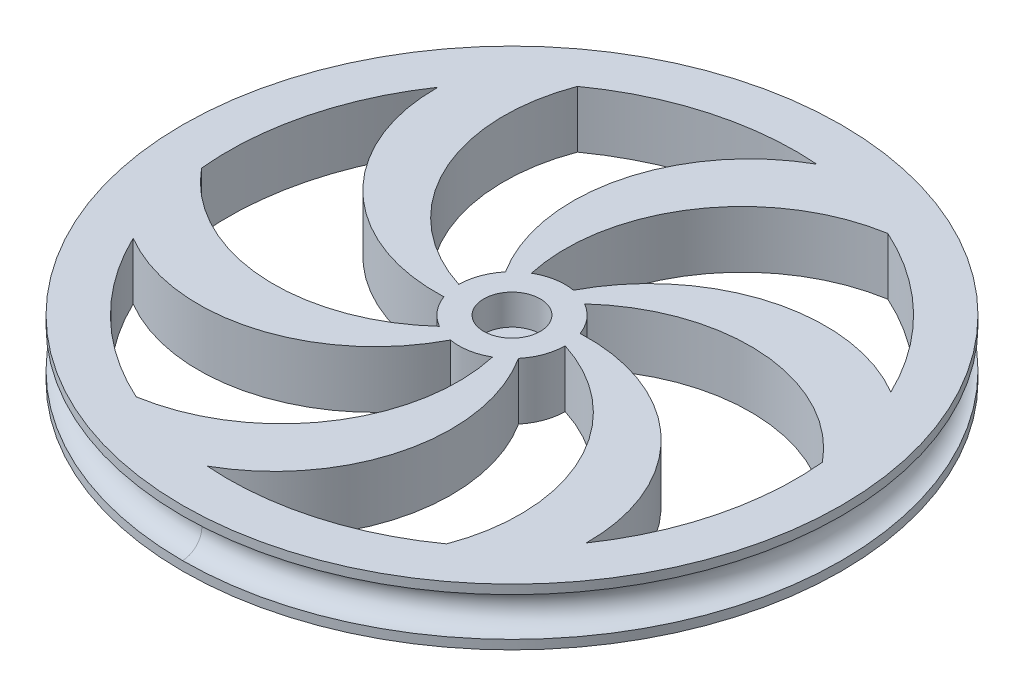
from build123d import *

# Parameters (mm, degrees)
SKETCH1_R                   = 27.559
BOSS_EXTRUDE1_DEPTH         = 4.7625
SKETCH2_R                   = 1.61925
F_40_0_098_DIAMETER_HOLE1_D = 2.4892
CUT_EXTRUDE1_DEPTH          = 40.264212309
SKETCH9_R                   = 2.3622
CUT_EXTRUDE2_DEPTH          = 2.54


with BuildPart() as part:
    # Sketch1 → Boss-Extrude1 (new body)
    with BuildSketch(Plane(origin=(0, 0, 0), x_dir=(1, 0, 0), z_dir=(0, 1, 0))):
        with Locations(Location((0, 0, 0), (0, 0, 270))):
            Circle(SKETCH1_R)
    extrude(amount=BOSS_EXTRUDE1_DEPTH)

    # Cut-Sweep1: sweep along a curve in space
    with BuildLine() as cut_sweep1_path:
        ThreePointArc((0, 0, 27.559), (19.487155783, 0, 19.487155783), (27.559, 0, 0))
        ThreePointArc((27.559, 0, 0), (19.487155783, 0, -19.487155783), (0, 0, -27.559))
        ThreePointArc((0, 0, -27.559), (-19.487155783, 0, -19.487155783), (-27.559, 0, 0))
        ThreePointArc((-27.559, 0, 0), (-19.487155783, 0, 19.487155783), (0, 0, 27.559))
    # Sketch2 → Cut-Sweep1 (sweep, cut)
    with BuildSketch(Plane.XY):
        with Locations((-27.559, 2.38125)):
            Circle(SKETCH2_R)
    sweep(path=cut_sweep1_path.line, mode=Mode.SUBTRACT)

    # #40 (0.098) Diameter Hole1 (through all)
    with Locations(Plane(origin=(0, 0, 0), x_dir=(0, 0, -1), z_dir=(0, -1, 0))):
        with Locations((0, 0)):
            Hole(F_40_0_098_DIAMETER_HOLE1_D / 2)

    # Sketch7 → Cut-Extrude1 (cut, through all)
    with BuildSketch(Plane(origin=(0, 4.7625, 0), x_dir=(1, 0, 0), z_dir=(0, 1, 0))):
        with BuildLine():
            ThreePointArc((-2.2225, 3.84948292), (-0.77186615, 4.377470462), (0.77186615, 4.377470462))
            ThreePointArc((0.77186615, 4.377470462), (9.824364413, 11.765183037), (21.41292145, 10.271406718))
            ThreePointArc((21.41292145, 10.271406718), (16.608536278, 16.975615562), (9.800916515, 21.632314635))
            ThreePointArc((9.800916515, 21.632314635), (-0.036614117, 15.327632806), (-2.2225, 3.84948292))
        make_face()
        with BuildLine():
            ThreePointArc((2.2225, 3.84948292), (3.40506755, 2.857190925), (4.176933699, 1.520279537))
            ThreePointArc((4.176933699, 1.520279537), (15.101129597, -2.625557639), (19.601759876, -13.408430586))
            ThreePointArc((19.601759876, -13.408430586), (22.688512471, -7.017578133), (23.749, 0))
            ThreePointArc((23.749, 0), (23.720380824, 1.1655619), (23.634592274, 2.328314635))
            ThreePointArc((23.634592274, 2.328314635), (13.255812331, 7.695525158), (2.2225, 3.84948292))
        make_face()
        with BuildLine():
            ThreePointArc((13.833675759, -19.304), (13.292426448, -7.632107648), (4.445, 0))
            ThreePointArc((4.445, 0), (4.176933699, -1.520279537), (3.40506755, -2.857190925))
            ThreePointArc((3.40506755, -2.857190925), (5.276765184, -14.390740676), (-1.811161574, -23.679837304))
            ThreePointArc((-1.811161574, -23.679837304), (6.397046182, -22.871222117), (13.833675759, -19.304))
        make_face()
        with BuildLine():
            ThreePointArc((-9.800916515, -21.632314635), (0.036614117, -15.327632806), (2.2225, -3.84948292))
            ThreePointArc((2.2225, -3.84948292), (0.77186615, -4.377470462), (-0.77186615, -4.377470462))
            ThreePointArc((-0.77186615, -4.377470462), (-9.824364413, -11.765183037), (-21.41292145, -10.271406718))
            ThreePointArc((-21.41292145, -10.271406718), (-16.608536278, -16.975615562), (-9.800916515, -21.632314635))
        make_face()
        with BuildLine():
            ThreePointArc((-23.634592274, -2.328314635), (-13.255812331, -7.695525158), (-2.2225, -3.84948292))
            ThreePointArc((-2.2225, -3.84948292), (-3.40506755, -2.857190925), (-4.176933699, -1.520279537))
            ThreePointArc((-4.176933699, -1.520279537), (-15.101129597, 2.625557639), (-19.601759876, 13.408430586))
            ThreePointArc((-19.601759876, 13.408430586), (-23.00558246, 5.895606556), (-23.634592274, -2.328314635))
        make_face()
        with BuildLine():
            ThreePointArc((-4.445, 0), (-4.176933699, 1.520279537), (-3.40506755, 2.857190925))
            ThreePointArc((-3.40506755, 2.857190925), (-5.276765184, 14.390740676), (1.811161574, 23.679837304))
            ThreePointArc((1.811161574, 23.679837304), (-6.397046182, 22.871222117), (-13.833675759, 19.304))
            ThreePointArc((-13.833675759, 19.304), (-13.292426448, 7.632107648), (-4.445, 0))
        make_face()
    extrude(amount=-CUT_EXTRUDE1_DEPTH, mode=Mode.SUBTRACT)

    # Sketch9 → Cut-Extrude2 (cut)
    with BuildSketch(Plane(origin=(0, 4.7625, 0), x_dir=(1, 0, 0), z_dir=(0, 1, 0))):
        with Locations(Location((0, 0, 0), (0, 0, 270))):
            Circle(SKETCH9_R)
    extrude(amount=-CUT_EXTRUDE2_DEPTH, mode=Mode.SUBTRACT)


solid = part.part
